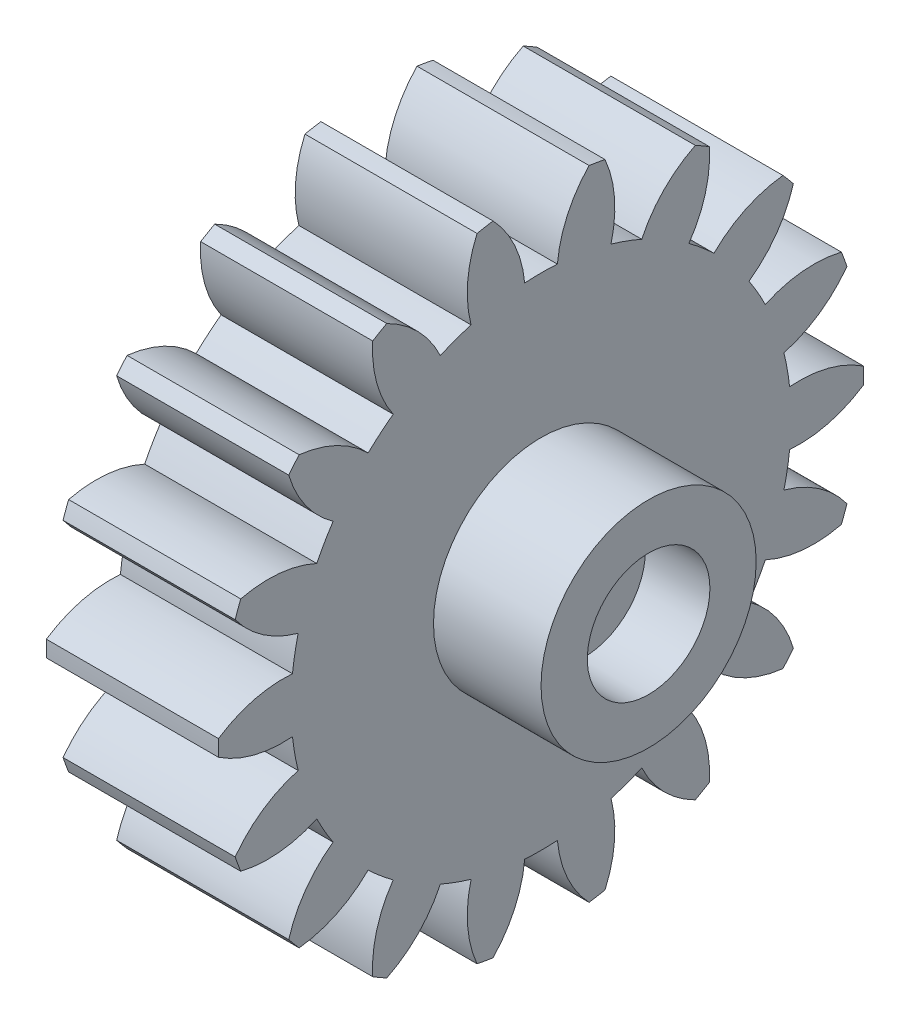
from build123d import *

# Parameters (mm, degrees)
BASPROSKE_W             = 8
BASPROSKE_H             = 15
TOOTHCUT_DEPTH          = 23.671568097
TEETHCUTS_COUNT         = 18
TEETHCUTS_ANGLE         = 340
BORSKE_R                = 0.4
BORE_DEPTH              = 50.0000508
ESQUISSE1_R             = 5
BOSS_EXTRU_1_DEPTH      = 5
ESQUISSE2_R             = 2.85
ENL_V_MAT_EXTRU_1_DEPTH = 3
ESQUISSE3_R             = 1
ENL_V_MAT_EXTRU_2_DEPTH = 24.345559985


with BuildPart() as part:
    # BasProSke → Base-Revolve (revolve)
    with BuildSketch(Plane(origin=(0, 0, 0), x_dir=(1, 0, 0), z_dir=(0, 1, 0)), mode=Mode.PRIVATE) as base_revolve_sk:
        with Locations((4, 7.5)):
            Rectangle(BASPROSKE_W, BASPROSKE_H)
    revolve(base_revolve_sk.sketch.rotate(Axis((-10, 0, 0), (1, 0, 0)), 180), axis=Axis((-10, 0, 0), (1, 0, 0)))

    # TooCutSke → ToothCut (cut, through all)
    with BuildSketch(Plane(origin=(0, 0, 0), x_dir=(0, 0, -1), z_dir=(1, 0, 0))):
        with BuildLine():
            ThreePointArc((0.759974923, 11.599129886), (0, 11.624), (-0.759974923, 11.599129886))
            ThreePointArc((-0.759974923, 11.599129886), (-1.229186471, 13.354767823), (-2.254227748, 14.855339189))
            ThreePointArc((-2.254227748, 14.855339189), (0, 15.0254), (2.254227748, 14.855339189))
            ThreePointArc((2.254227748, 14.855339189), (1.229186471, 13.354767823), (0.759974923, 11.599129886))
        make_face()
    toothcut = extrude(amount=TOOTHCUT_DEPTH, mode=Mode.SUBTRACT)

    # TeethCuts: ToothCut ×18 about axis
    teethcuts_axis = Axis((-10, 0, 0), (1, 0, 0))
    for i in range(1, TEETHCUTS_COUNT):
        add(toothcut.rotate(teethcuts_axis, i * TEETHCUTS_ANGLE / (TEETHCUTS_COUNT - 1)), mode=Mode.SUBTRACT)

    # BorSke → Bore (cut, symmetric)
    with BuildSketch(Plane(origin=(0, 0, 0), x_dir=(0, 0, -1), z_dir=(1, 0, 0))):
        with Locations(Location((0, 0, 0), (0, 0, 180))):
            Circle(BORSKE_R)
    extrude(amount=BORE_DEPTH, both=True, mode=Mode.SUBTRACT)

    # Esquisse1 → Boss.-Extru.1 (add)
    with BuildSketch(Plane(origin=(8, 0, 0), x_dir=(0, 0, -1), z_dir=(1, 0, 0))):
        with Locations(Location((0, 0, 0), (0, 0, 180))):
            Circle(ESQUISSE1_R)
    extrude(amount=BOSS_EXTRU_1_DEPTH)

    # Esquisse2 → Enlèv. mat.-Extru.1 (cut)
    with BuildSketch(Plane(origin=(13, 0, 0), x_dir=(0, 0, -1), z_dir=(1, 0, 0))):
        Circle(ESQUISSE2_R)
    extrude(amount=-ENL_V_MAT_EXTRU_1_DEPTH, mode=Mode.SUBTRACT)

    # Esquisse3 → Enlèv. mat.-Extru.2 (cut, through all)
    with BuildSketch(Plane(origin=(10, 0, 0), x_dir=(0, 0, -1), z_dir=(1, 0, 0))):
        Circle(ESQUISSE3_R)
    extrude(amount=-ENL_V_MAT_EXTRU_2_DEPTH, mode=Mode.SUBTRACT)


solid = part.part
